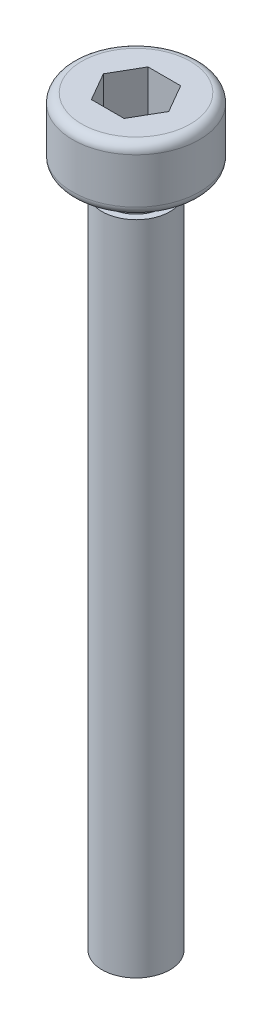
from build123d import *

# Parameters (mm, degrees)
CUT_EXTRUDE_1_DEPTH = 2


with BuildPart() as part:
    # 草图1 → 旋转1 (revolve)
    with BuildSketch(Plane.XY):
        with BuildLine():
            Line((0, 32.8), (-2.4, 32.8))
            ThreePointArc((-2.4, 32.8), (-2.682842712, 32.682842712), (-2.8, 32.4))
            Line((-2.8, 32.4), (-2.8, 30.4))
            ThreePointArc((-2.8, 30.4), (-2.682842712, 30.117157288), (-2.4, 30))
            Line((-2.4, 30), (-1.2, 30))
            Line((-1.2, 30), (-1.2, 29))
            Line((-1.2, 29), (-1.5, 29))
            Line((-1.5, 29), (-1.5, 0))
            Line((-1.5, 0), (0, 0))
            Line((0, 0), (0, 32.8))
        make_face()
    revolve(axis=Axis((0, 0, 0), (0, 1, 0)))

    # 草图2 → 切除-拉伸1 (cut)
    with BuildSketch(Plane(origin=(0, 32.8, 0), x_dir=(1, 0, 0), z_dir=(0, 1, 0))):
        Polygon((-0.721687836, 1.25), (-1.443375673, 0), (-0.721687836, -1.25), (0.721687836, -1.25), (1.443375673, 0), (0.721687836, 1.25), align=None)
    extrude(amount=-CUT_EXTRUDE_1_DEPTH, mode=Mode.SUBTRACT)


solid = part.part
